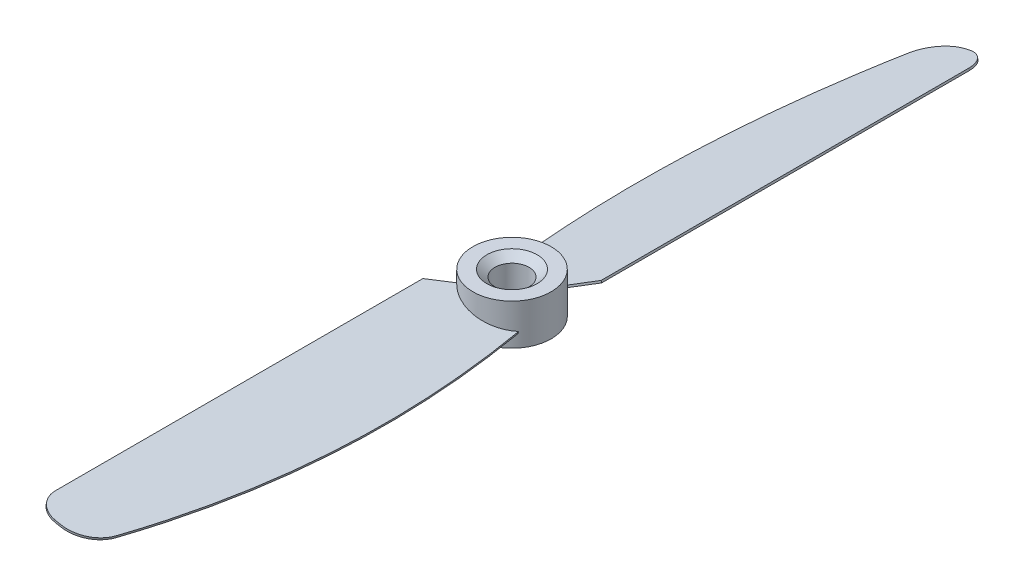
from build123d import *

# Parameters (mm, degrees)
SKETCH1_R             = 5.75
BOSS_EXTRUDE1_DEPTH   = 3
BOSS_EXTRUDE2_DEPTH   = 0.15
CIRPATTERN1_COUNT     = 2
SKETCH4_R             = 2.5
CUT_EXTRUDE1_DEPTH    = 7.0000001
CHAMFER1_SIZE         = 1
CHAMFER1_SIZE2        = 1.191753593
CHAMFER1_PART_2_SIZE  = 1
CHAMFER1_PART_2_SIZE2 = 1.191753593


with BuildPart() as part:
    # Sketch1 → Boss-Extrude1 (new body, symmetric)
    with BuildSketch(Plane(origin=(0, 0, 0), x_dir=(1, 0, 0), z_dir=(0, 1, 0))):
        Circle(SKETCH1_R)
    extrude(amount=BOSS_EXTRUDE1_DEPTH, both=True)

    # Sketch3 → Boss-Extrude2 (add, symmetric)
    with BuildSketch(Plane(origin=(0, 0, 0), x_dir=(0.974370065, -0.224951054, 0), z_dir=(-0.224951054, -0.974370065, 0))):
        with BuildLine():
            Line((-3.842130485, 3.401744966), (-6.87806753, 6.437682011))
            Line((-6.87806753, 6.437682011), (-6.87806753, 60.5))
            ThreePointArc((-6.87806753, 60.5), (-5.999387873, 62.621320344), (-3.87806753, 63.5))
            Line((-3.87806753, 63.5), (-3.193113424, 63.5))
            ThreePointArc((-3.193113424, 63.5), (-0.110101392, 62.436373561), (1.661241396, 59.698014726))
            add(Edge.make_bspline(
                [(1.661241396, 59.698014726), (9.030851791, 31.313089237), (4.404985301, 2.253493698)],
                knots=[0, 0, 0, 1, 1, 1], degree=2))
            add(Edge.make_bspline(
                [(-3.842130485, 3.401744966), (0.406766217, 7.300677946), (4.404985301, 2.253493698)],
                knots=[0, 0, 0, 1, 1, 1], degree=2))
        make_face()
    boss_extrude2 = extrude(amount=BOSS_EXTRUDE2_DEPTH, both=True)

    # CirPattern1: Boss-Extrude2 ×2 about axis
    cirpattern1_axis = Axis((0, 3, 0), (0, -1, 0))
    for i in range(1, CIRPATTERN1_COUNT):
        add(boss_extrude2.rotate(cirpattern1_axis, i * 360 / CIRPATTERN1_COUNT))

    # Sketch4 → Cut-Extrude1 (cut, through all)
    with BuildSketch(Plane.XZ.offset(3)):
        Circle(SKETCH4_R)
    extrude(amount=-CUT_EXTRUDE1_DEPTH, mode=Mode.SUBTRACT)

    # Chamfer1
    chamfer1_edges = [part.edges().sort_by_distance(p)[0] for p in [
        (-2.5, 3, 0),
    ]]
    chamfer1_side = [part.faces().sort_by_distance(p)[0] for p in [
        (-2.5, 0, 0),
    ]]
    chamfer(chamfer1_edges, length=CHAMFER1_SIZE, length2=CHAMFER1_SIZE2, reference=chamfer1_side[0])

    # Chamfer1 part 2
    chamfer1_part_2_edges = [part.edges().sort_by_distance(p)[0] for p in [
        (-2.5, -3, 0),
    ]]
    chamfer1_part_2_side = [part.faces().sort_by_distance(p)[0] for p in [
        (-5.58736544, -3, 0),
    ]]
    chamfer(chamfer1_part_2_edges, length=CHAMFER1_PART_2_SIZE, length2=CHAMFER1_PART_2_SIZE2, reference=chamfer1_part_2_side[0])


solid = part.part
